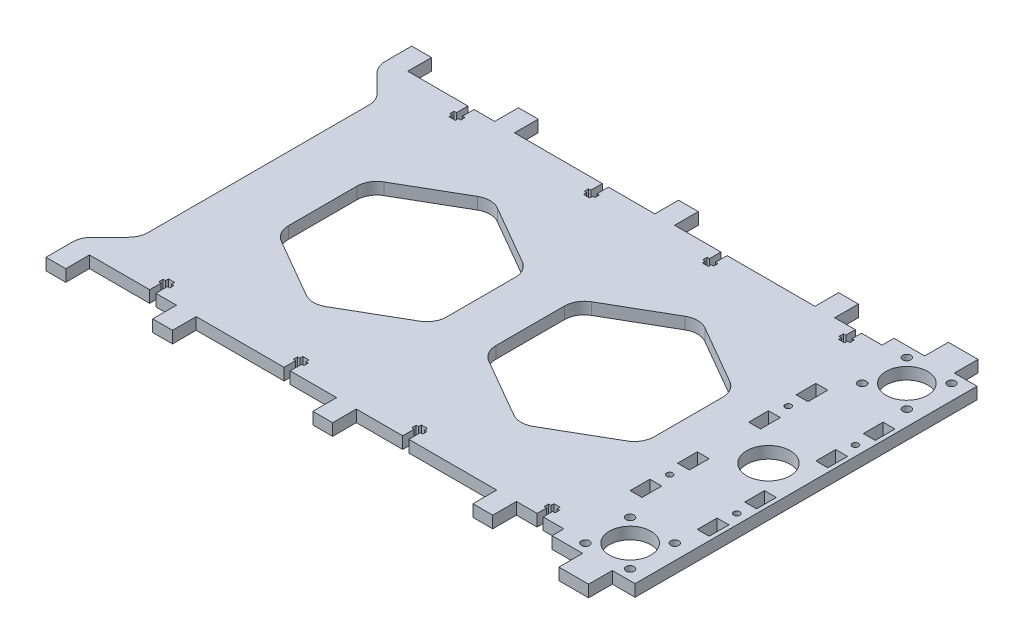
from build123d import *

# Parameters (mm, degrees)
SKETCH_1_R      = 1.55
SKETCH_1_R_2    = 2.05
SKETCH_1_R_3    = 10.5
SKETCH_1_R_4    = 11
SKETCH_1_W      = 6.000012159
SKETCH_1_H      = 9.999999777
SKETCH_1_H_2    = 9.999997914
SKETCH_1_W_2    = 5.999997258
EXTRUDE_1_DEPTH = 6


with BuildPart() as part:
    # Эскиз1 → Бобышка-Вытянуть1 (new body)
    with BuildSketch(Plane(origin=(0, 0, 0), x_dir=(1, 0, 0), z_dir=(0, 1, 0))):
        with BuildLine():
            Line((-130.221094168, -56.247315921), (-130.221094168, 55.468411732))
            ThreePointArc((-130.221094168, 55.468411732), (-130.982298633, 59.295246647), (-133.150026356, 62.539480643))
            Line((-133.150026356, 62.539480643), (-142.292167223, 71.681616444))
            ThreePointArc((-142.292167223, 71.681616444), (-144.459893148, 74.925849574), (-145.221097226, 78.752682812))
            Line((-145.221097226, 78.752682812), (-145.221097822, 92.11054838))
            Line((-145.221097822, 92.11054838), (-135.221092458, 92.11054838))
            Line((-135.221092458, 92.11054838), (-135.221092458, 80.110546414))
            Line((-135.221092458, 80.110546414), (-104.771098549, 80.110546414))
            Line((-104.771098549, 80.110546414), (-104.771098549, 74.31054509))
            Line((-104.771098549, 74.31054509), (-105.971096511, 74.31054509))
            Line((-105.971096511, 74.31054509), (-105.971096511, 72.110545102))
            Line((-105.971096511, 72.110545102), (-104.771098549, 72.110545102))
            Line((-104.771098549, 72.110545102), (-104.771098549, 70.610549513))
            Line((-104.771098549, 70.610549513), (-101.671098227, 70.610549513))
            Line((-101.671098227, 70.610549513), (-101.671098227, 72.110545102))
            Line((-101.671098227, 72.110545102), (-100.471100266, 72.110545102))
            Line((-100.471100266, 72.110545102), (-100.471100266, 74.31054509))
            Line((-100.471100266, 74.31054509), (-101.671098227, 74.31054509))
            Line((-101.671098227, 74.31054509), (-101.671098227, 80.110546414))
            Line((-101.671098227, 80.110546414), (-91.221100147, 80.110546414))
            Line((-91.221100147, 80.110546414), (-91.221100147, 92.11054838))
            Line((-91.221100147, 92.11054838), (-81.221094782, 92.11054838))
            Line((-81.221094782, 92.11054838), (-81.221094782, 80.110546414))
            Line((-81.221094782, 80.110546414), (-36.771098579, 80.110546414))
            Line((-36.771098579, 80.110546414), (-36.771098579, 74.31054509))
            Line((-36.771098579, 74.31054509), (-37.97109654, 74.31054509))
            Line((-37.97109654, 74.31054509), (-37.97109654, 72.110545102))
            Line((-37.97109654, 72.110545102), (-36.771098579, 72.110545102))
            Line((-36.771098579, 72.110545102), (-36.771098579, 70.610549513))
            Line((-36.771098579, 70.610549513), (-33.671096394, 70.610549513))
            Line((-33.671096394, 70.610549513), (-33.671096394, 72.110545102))
            Line((-33.671096394, 72.110545102), (-32.47109657, 72.110545102))
            Line((-32.47109657, 72.110545102), (-32.47109657, 74.31054509))
            Line((-32.47109657, 74.31054509), (-33.671096394, 74.31054509))
            Line((-33.671096394, 74.31054509), (-33.671096394, 80.110546414))
            Line((-33.671096394, 80.110546414), (-10.221097114, 80.110546414))
            Line((-10.221097114, 80.110546414), (-10.221097114, 92.11054838))
            Line((-10.221097114, 92.11054838), (-0.221097338, 92.11054838))
            Line((-0.221097338, 92.11054838), (-0.221097338, 80.110546414))
            Line((-0.221097338, 80.110546414), (23.228901943, 80.110546414))
            Line((23.228901943, 80.110546414), (23.228901943, 74.31054509))
            Line((23.228901943, 74.31054509), (22.028902118, 74.31054509))
            Line((22.028902118, 74.31054509), (22.028902118, 72.110545102))
            Line((22.028902118, 72.110545102), (23.228901943, 72.110545102))
            Line((23.228901943, 72.110545102), (23.228901943, 70.610549513))
            Line((23.228901943, 70.610549513), (26.328904127, 70.610549513))
            Line((26.328904127, 70.610549513), (26.328904127, 72.110545102))
            Line((26.328904127, 72.110545102), (27.528902089, 72.110545102))
            Line((27.528902089, 72.110545102), (27.528902089, 74.31054509))
            Line((27.528902089, 74.31054509), (26.328904127, 74.31054509))
            Line((26.328904127, 74.31054509), (26.328904127, 80.110546414))
            Line((26.328904127, 80.110546414), (70.77890033, 80.110546414))
            Line((70.77890033, 80.110546414), (70.77890033, 92.11054838))
            Line((70.77890033, 92.11054838), (80.778905695, 92.11054838))
            Line((80.778905695, 92.11054838), (80.778905695, 80.110546414))
            Line((80.778905695, 80.110546414), (91.228903775, 80.110546414))
            Line((91.228903775, 80.110546414), (91.228903775, 75.310547117))
            Line((91.228903775, 75.310547117), (90.028905814, 75.310547117))
            Line((90.028905814, 75.310547117), (90.028905814, 73.110547129))
            Line((90.028905814, 73.110547129), (91.228903775, 73.110547129))
            Line((91.228903775, 73.110547129), (91.228903775, 71.610544089))
            Line((91.228903775, 71.610544089), (94.328904097, 71.610544089))
            Line((94.328904097, 71.610544089), (94.328904097, 73.110547129))
            Line((94.328904097, 73.110547129), (95.528902059, 73.110547129))
            Line((95.528902059, 73.110547129), (95.528902059, 75.310547117))
            Line((95.528902059, 75.310547117), (94.328904097, 75.310547117))
            Line((94.328904097, 75.310547117), (94.328904097, 80.110546414))
            Line((94.328904097, 80.110546414), (104.778902178, 80.110546414))
            Line((104.778902178, 80.110546414), (104.778902178, 86.110543672))
            Line((104.778902178, 86.110543672), (120.278896337, 86.110543672))
            Line((120.278896337, 86.110543672), (120.278896337, 98.110545639))
            Line((120.278896337, 98.110545639), (135.278896933, 98.110545639))
            Line((135.278896933, 98.110545639), (135.278896933, 86.110543672))
            Line((135.278896933, 86.110543672), (146.778900944, 86.110543672))
            Line((146.778900944, 86.110543672), (146.778900944, -86.889448028))
            Line((146.778900944, -86.889448028), (135.278899991, -86.889448028))
            Line((135.278899991, -86.889448028), (135.278899991, -98.889449995))
            Line((135.278899991, -98.889449995), (120.278899395, -98.889449995))
            Line((120.278899395, -98.889449995), (120.278899395, -86.889448028))
            Line((120.278899395, -86.889448028), (104.778905236, -86.889448028))
            Line((104.778905236, -86.889448028), (104.778905236, -80.88945077))
            Line((104.778905236, -80.88945077), (94.328907155, -80.88945077))
            Line((94.328907155, -80.88945077), (94.328907155, -76.089451474))
            Line((94.328907155, -76.089451474), (95.528905117, -76.089451474))
            Line((95.528905117, -76.089451474), (95.528905117, -73.889451485))
            Line((95.528905117, -73.889451485), (94.328907155, -73.889451485))
            Line((94.328907155, -73.889451485), (94.328907155, -72.389448446))
            Line((94.328907155, -72.389448446), (91.228906833, -72.389448446))
            Line((91.228906833, -72.389448446), (91.228906833, -73.889451485))
            Line((91.228906833, -73.889451485), (90.028908872, -73.889451485))
            Line((90.028908872, -73.889451485), (90.028908872, -76.089451474))
            Line((90.028908872, -76.089451474), (91.228906833, -76.089451474))
            Line((91.228906833, -76.089451474), (91.228906833, -80.88945077))
            Line((91.228906833, -80.88945077), (80.778908753, -80.88945077))
            Line((80.778908753, -80.88945077), (80.778908753, -92.889452737))
            Line((80.778908753, -92.889452737), (70.778903388, -92.889452737))
            Line((70.778903388, -92.889452737), (70.778903388, -80.88945077))
            Line((70.778903388, -80.88945077), (26.328907185, -80.88945077))
            Line((26.328907185, -80.88945077), (26.328907185, -75.089449447))
            Line((26.328907185, -75.089449447), (27.528905146, -75.089449447))
            Line((27.528905146, -75.089449447), (27.528905146, -72.889449459))
            Line((27.528905146, -72.889449459), (26.328907185, -72.889449459))
            Line((26.328907185, -72.889449459), (26.328907185, -71.38945387))
            Line((26.328907185, -71.38945387), (23.228905, -71.38945387))
            Line((23.228905, -71.38945387), (23.228905, -72.889449459))
            Line((23.228905, -72.889449459), (22.028905176, -72.889449459))
            Line((22.028905176, -72.889449459), (22.028905176, -75.089449447))
            Line((22.028905176, -75.089449447), (23.228905, -75.089449447))
            Line((23.228905, -75.089449447), (23.228905, -80.88945077))
            Line((23.228905, -80.88945077), (-0.22109428, -80.88945077))
            Line((-0.22109428, -80.88945077), (-0.22109428, -92.889452737))
            Line((-0.22109428, -92.889452737), (-10.221094056, -92.889452737))
            Line((-10.221094056, -92.889452737), (-10.221094056, -80.88945077))
            Line((-10.221094056, -80.88945077), (-33.671093337, -80.88945077))
            Line((-33.671093337, -80.88945077), (-33.671093337, -75.089449447))
            Line((-33.671093337, -75.089449447), (-32.471093512, -75.089449447))
            Line((-32.471093512, -75.089449447), (-32.471093512, -72.889449459))
            Line((-32.471093512, -72.889449459), (-33.671093337, -72.889449459))
            Line((-33.671093337, -72.889449459), (-33.671093337, -71.38945387))
            Line((-33.671093337, -71.38945387), (-36.771095521, -71.38945387))
            Line((-36.771095521, -71.38945387), (-36.771095521, -72.889449459))
            Line((-36.771095521, -72.889449459), (-37.971093483, -72.889449459))
            Line((-37.971093483, -72.889449459), (-37.971093483, -75.089449447))
            Line((-37.971093483, -75.089449447), (-36.771095521, -75.089449447))
            Line((-36.771095521, -75.089449447), (-36.771095521, -80.88945077))
            Line((-36.771095521, -80.88945077), (-81.221091724, -80.88945077))
            Line((-81.221091724, -80.88945077), (-81.221091724, -92.889452737))
            Line((-81.221091724, -92.889452737), (-91.221097089, -92.889452737))
            Line((-91.221097089, -92.889452737), (-91.221097089, -80.88945077))
            Line((-91.221097089, -80.88945077), (-101.671095169, -80.88945077))
            Line((-101.671095169, -80.88945077), (-101.671095169, -75.089449447))
            Line((-101.671095169, -75.089449447), (-100.471097208, -75.089449447))
            Line((-100.471097208, -75.089449447), (-100.471097208, -72.889449459))
            Line((-100.471097208, -72.889449459), (-101.671095169, -72.889449459))
            Line((-101.671095169, -72.889449459), (-101.671095169, -71.38945387))
            Line((-101.671095169, -71.38945387), (-104.771095491, -71.38945387))
            Line((-104.771095491, -71.38945387), (-104.771095491, -72.889449459))
            Line((-104.771095491, -72.889449459), (-105.971093453, -72.889449459))
            Line((-105.971093453, -72.889449459), (-105.971093453, -75.089449447))
            Line((-105.971093453, -75.089449447), (-104.771095491, -75.089449447))
            Line((-104.771095491, -75.089449447), (-104.771095491, -80.88945077))
            Line((-104.771095491, -80.88945077), (-135.2210894, -80.88945077))
            Line((-135.2210894, -80.88945077), (-135.2210894, -92.889452737))
            Line((-135.2210894, -92.889452737), (-145.221094764, -92.889452737))
            Line((-145.221094764, -92.889452737), (-145.221094168, -79.531587169))
            ThreePointArc((-145.221094168, -79.531587169), (-144.459889493, -75.704752845), (-142.29216198, -72.460519357))
            Line((-142.29216198, -72.460519357), (-133.150026356, -63.318383733))
            ThreePointArc((-133.150026356, -63.318383733), (-130.982298843, -60.074150245), (-130.221094168, -56.247315921))
        make_face()
        with Locations((107.778905832, 29.610548455)):
            Circle(SKETCH_1_R, mode=Mode.SUBTRACT)
        with Locations((116.478905832, 58.310548455)):
            Circle(SKETCH_1_R_2, mode=Mode.SUBTRACT)
        with Locations((139.078905832, 58.310548455)):
            Circle(SKETCH_1_R_2, mode=Mode.SUBTRACT)
        with Locations((127.778905832, 69.610548455)):
            Circle(SKETCH_1_R_3, mode=Mode.SUBTRACT)
        with Locations((141.778905832, 29.610548455)):
            Circle(SKETCH_1_R, mode=Mode.SUBTRACT)
        with Locations((139.078905832, 80.910548455)):
            Circle(SKETCH_1_R_2, mode=Mode.SUBTRACT)
        with Locations((116.478905832, 80.910548455)):
            Circle(SKETCH_1_R_2, mode=Mode.SUBTRACT)
        with Locations((107.778905832, -30.389451545)):
            Circle(SKETCH_1_R, mode=Mode.SUBTRACT)
        with Locations((116.478905832, -59.089451545)):
            Circle(SKETCH_1_R_2, mode=Mode.SUBTRACT)
        with Locations((139.078905832, -59.089451545)):
            Circle(SKETCH_1_R_2, mode=Mode.SUBTRACT)
        with Locations((127.778905832, -70.389451545)):
            Circle(SKETCH_1_R_3, mode=Mode.SUBTRACT)
        with Locations((141.778905832, -30.389451545)):
            Circle(SKETCH_1_R, mode=Mode.SUBTRACT)
        with Locations((139.078905832, -81.689451545)):
            Circle(SKETCH_1_R_2, mode=Mode.SUBTRACT)
        with Locations((116.478905832, -81.689451545)):
            Circle(SKETCH_1_R_2, mode=Mode.SUBTRACT)
        with Locations((127.778905832, -0.389451545)):
            Circle(SKETCH_1_R_4, mode=Mode.SUBTRACT)
        with Locations((141.778905713, 17.610548612)):
            Rectangle(SKETCH_1_W, SKETCH_1_H, mode=Mode.SUBTRACT)
        with Locations((141.778905713, 41.610547889)):
            Rectangle(SKETCH_1_W, SKETCH_1_H_2, mode=Mode.SUBTRACT)
        with Locations((107.778903865, 41.610547889)):
            Rectangle(SKETCH_1_W_2, SKETCH_1_H_2, mode=Mode.SUBTRACT)
        with Locations((107.778903865, 17.610548612)):
            Rectangle(SKETCH_1_W_2, SKETCH_1_H, mode=Mode.SUBTRACT)
        with Locations((141.778905713, -18.389451702)):
            Rectangle(SKETCH_1_W, SKETCH_1_H, mode=Mode.SUBTRACT)
        with Locations((141.778905713, -42.389450979)):
            Rectangle(SKETCH_1_W, SKETCH_1_H_2, mode=Mode.SUBTRACT)
        with Locations((107.778903865, -42.389450979)):
            Rectangle(SKETCH_1_W_2, SKETCH_1_H_2, mode=Mode.SUBTRACT)
        with Locations((107.778903865, -18.389451702)):
            Rectangle(SKETCH_1_W_2, SKETCH_1_H, mode=Mode.SUBTRACT)
        with BuildLine():
            Line((-22.721095459, 25.591311206), (-52.721094676, 42.911818829))
            ThreePointArc((-52.721094676, 42.911818829), (-57.721094913, 44.251565218), (-62.721095272, 42.911819281))
            Line((-62.721095272, 42.911819281), (-92.721093782, 25.591310367))
            ThreePointArc((-92.721093782, 25.591310367), (-96.381348087, 21.93105654), (-97.721094168, 16.931056531))
            Line((-97.721094168, 16.931056531), (-97.72109536, -17.709959682))
            ThreePointArc((-97.72109536, -17.709959682), (-96.381349303, -22.709959945), (-92.721095062, -26.370214175))
            Line((-92.721095062, -26.370214175), (-62.721096181, -43.690721605))
            ThreePointArc((-62.721096181, -43.690721605), (-57.721095746, -45.030468202), (-52.721095138, -43.69072225))
            Line((-52.721095138, -43.69072225), (-22.721095212, -26.370213336))
            ThreePointArc((-22.721095212, -26.370213336), (-19.060841533, -22.709959462), (-17.721095711, -17.709959806))
            Line((-17.721095711, -17.709959806), (-17.721095711, 16.931056345))
            ThreePointArc((-17.721095711, 16.931056345), (-19.060841358, 21.931056768), (-22.721095459, 25.591311206))
        make_face(mode=Mode.SUBTRACT)
        with BuildLine():
            Line((12.278905832, -26.370213659), (42.278905048, -43.690721282))
            ThreePointArc((42.278905048, -43.690721282), (47.278905286, -45.030467671), (52.278905644, -43.690721734))
            Line((52.278905644, -43.690721734), (82.278904154, -26.37021282))
            ThreePointArc((82.278904154, -26.37021282), (85.939158459, -22.709958993), (87.278904541, -17.709958984))
            Line((87.278904541, -17.709958984), (87.278905733, 16.93105723))
            ThreePointArc((87.278905733, 16.93105723), (85.939159361, 21.93105707), (82.278905183, 25.591310899))
            Line((82.278905183, 25.591310899), (52.278906302, 42.911818329))
            ThreePointArc((52.278906302, 42.911818329), (47.278905867, 44.251564927), (42.278905259, 42.911818975))
            Line((42.278905259, 42.911818975), (12.278905334, 25.59131006))
            ThreePointArc((12.278905334, 25.59131006), (8.618651654, 21.931056186), (7.278905832, 16.931056531))
            Line((7.278905832, 16.931056531), (7.278905832, -17.709959621))
            ThreePointArc((7.278905832, -17.709959621), (8.618651794, -22.709959621), (12.278905832, -26.370213659))
        make_face(mode=Mode.SUBTRACT)
    extrude(amount=EXTRUDE_1_DEPTH)


solid = part.part
